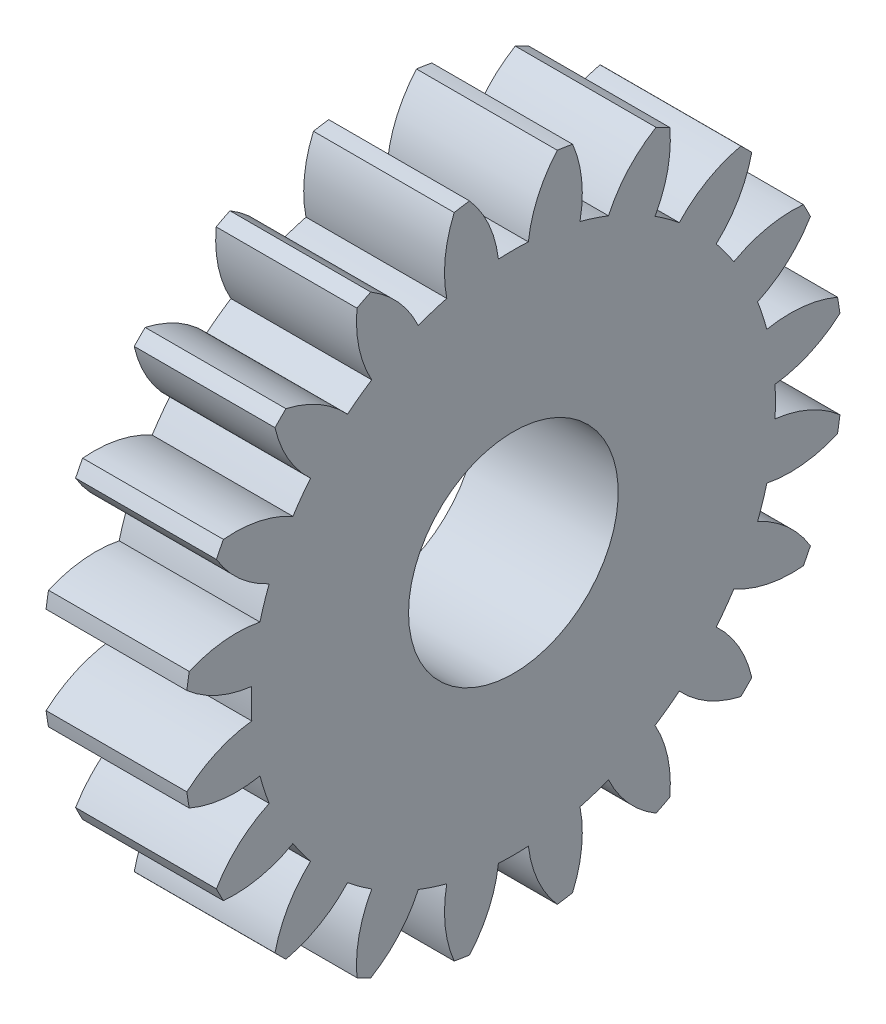
from build123d import *

# Parameters (mm, degrees)
BASPROSKE_W     = 4.7
BASPROSKE_H     = 11
TOOTHCUT_DEPTH  = 17.250846132
TEETHCUTS_COUNT = 20
TEETHCUTS_ANGLE = 342
BORSKE_R        = 3.5
BORE_DEPTH      = 50.0000508


with BuildPart() as part:
    # BasProSke → Base-Revolve (revolve)
    with BuildSketch(Plane(origin=(0, 0, 0), x_dir=(1, 0, 0), z_dir=(0, 1, 0)), mode=Mode.PRIVATE) as base_revolve_sk:
        with Locations((2.35, 5.5)):
            Rectangle(BASPROSKE_W, BASPROSKE_H)
    revolve(base_revolve_sk.sketch.rotate(Axis((-10, 0, 0), (1, 0, 0)), 180), axis=Axis((-10, 0, 0), (1, 0, 0)))

    # TooCutSke → ToothCut (cut, through all)
    with BuildSketch(Plane(origin=(0, 0, 0), x_dir=(0, 0, -1), z_dir=(1, 0, 0))):
        with BuildLine():
            ThreePointArc((0.499924007, 8.734705318), (0, 8.749), (-0.499924007, 8.734705318))
            ThreePointArc((-0.499924007, 8.734705318), (-0.824302243, 9.905497836), (-1.485192705, 10.924909509))
            ThreePointArc((-1.485192705, 10.924909509), (0, 11.0254), (1.485192705, 10.924909509))
            ThreePointArc((1.485192705, 10.924909509), (0.824302243, 9.905497836), (0.499924007, 8.734705318))
        make_face()
    toothcut = extrude(amount=TOOTHCUT_DEPTH, mode=Mode.SUBTRACT)

    # TeethCuts: ToothCut ×20 about axis
    teethcuts_axis = Axis((-10, 0, 0), (1, 0, 0))
    for i in range(1, TEETHCUTS_COUNT):
        add(toothcut.rotate(teethcuts_axis, i * TEETHCUTS_ANGLE / (TEETHCUTS_COUNT - 1)), mode=Mode.SUBTRACT)

    # BorSke → Bore (cut, symmetric)
    with BuildSketch(Plane(origin=(0, 0, 0), x_dir=(0, 0, -1), z_dir=(1, 0, 0))):
        with Locations(Location((0, 0, 0), (0, 0, 180))):
            Circle(BORSKE_R)
    extrude(amount=BORE_DEPTH, both=True, mode=Mode.SUBTRACT)


solid = part.part
